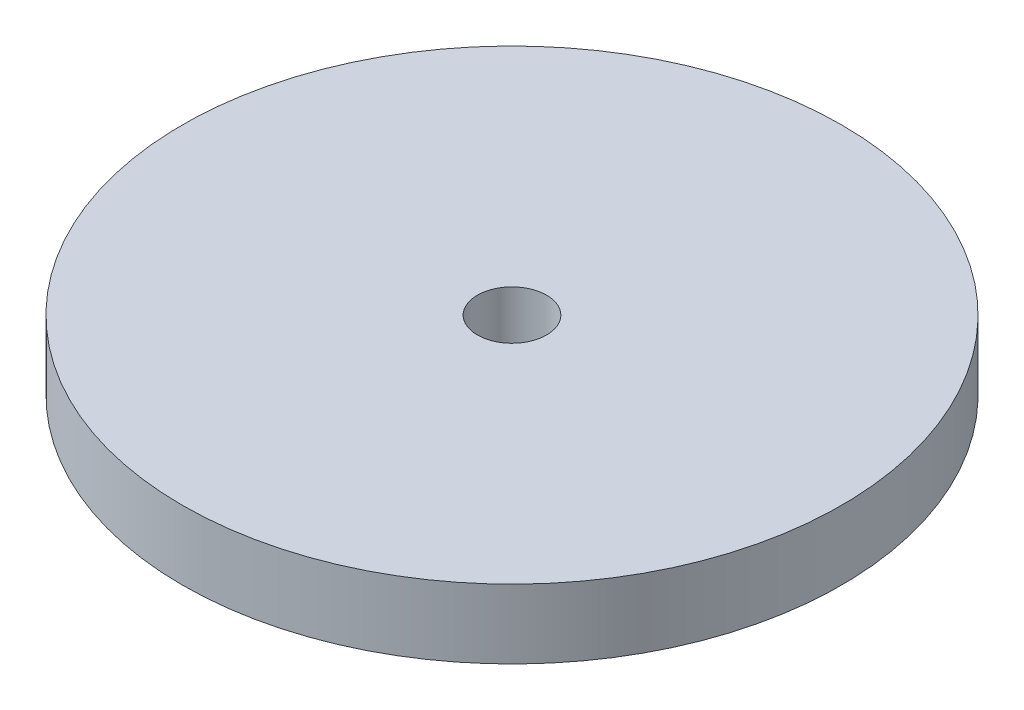
from build123d import *

# Parameters (mm, degrees)
SKETCH1_R           = 14.3
SKETCH1_R_2         = 1.5
BOSS_EXTRUDE1_DEPTH = 3


with BuildPart() as part:
    # Sketch1 → Boss-Extrude1 (new body)
    with BuildSketch(Plane(origin=(0, 0, 0), x_dir=(1, 0, 0), z_dir=(0, 1, 0))):
        Circle(SKETCH1_R)
        Circle(SKETCH1_R_2, mode=Mode.SUBTRACT)
    extrude(amount=BOSS_EXTRUDE1_DEPTH)


solid = part.part
